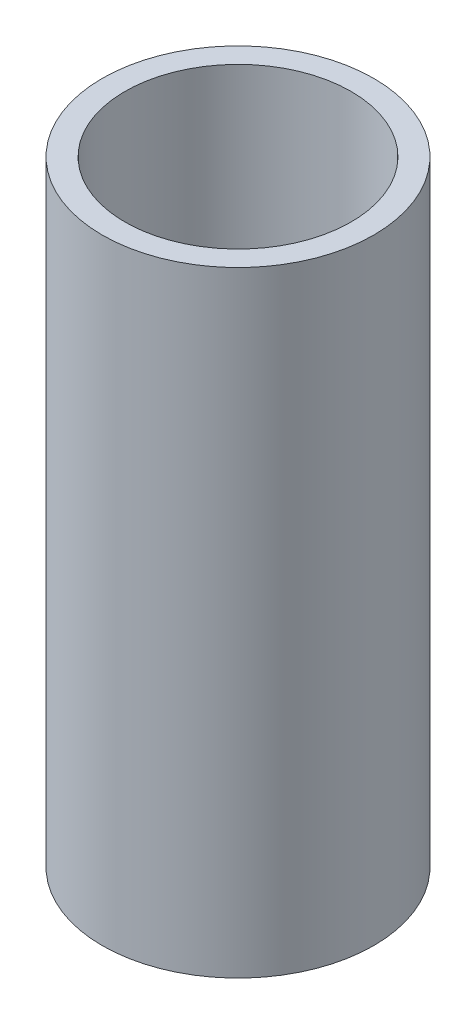
from build123d import *

# Parameters (mm, degrees)
CROQUIS1_W = 8.75
CROQUIS1_H = 238


with BuildPart() as part:
    # Croquis1 → Revolución1 (revolve)
    with BuildSketch(Plane.XY):
        with Locations((-48.125, 119)):
            Rectangle(CROQUIS1_W, CROQUIS1_H)
    revolve(axis=Axis((0, 0, 0), (0, 1, 0)))


solid = part.part
